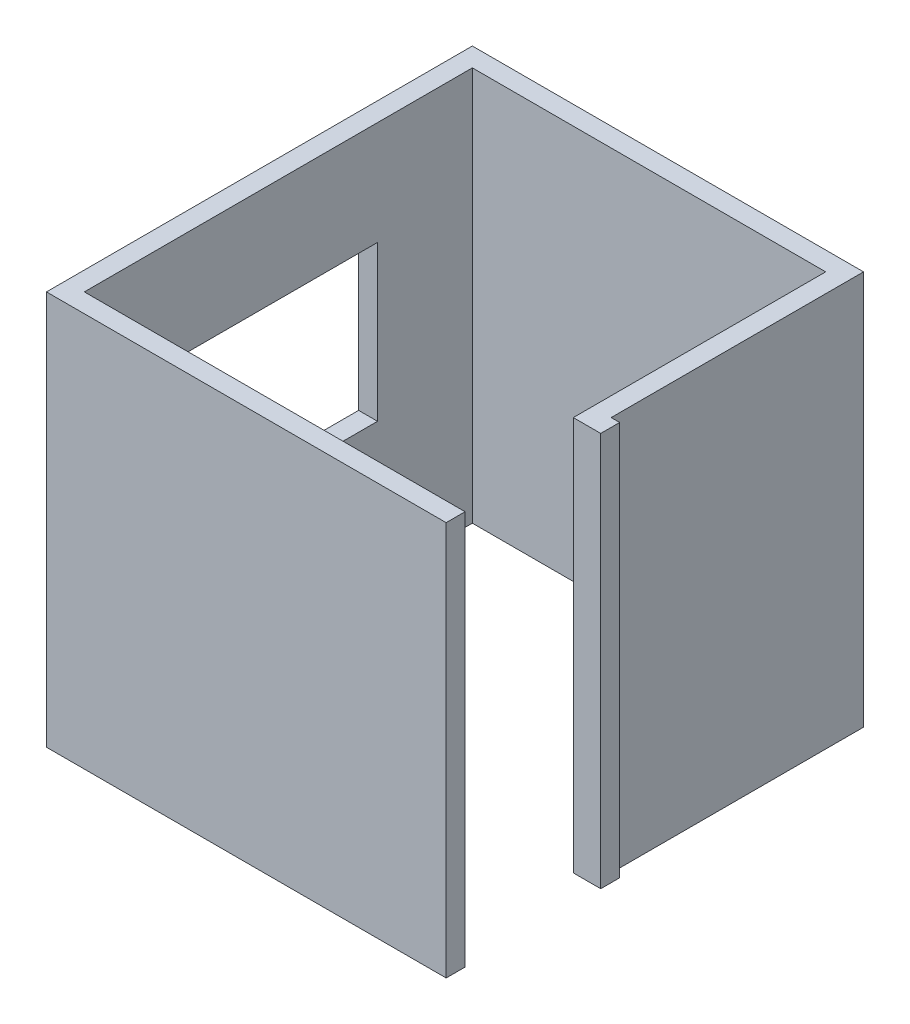
from build123d import *

# Parameters (mm, degrees)
EXTRUDE_1_DEPTH     = 2500
CUT_EXTRUDE_1_REACH = 2535.941
SKETCH_2_W          = 1370
SKETCH_2_H          = 982.146059398


with BuildPart() as part:
    # Эскиз1 → Вытянуть-Тонкостенный1 (new body)
    with BuildSketch(Plane(origin=(0, 0, 0), x_dir=(1, 0, 0), z_dir=(0, 1, 0))):
        Polygon((2413.940825756, 0), (0, 0), (0, 2460), (2240, 2460), (2240, 860), (2413.940825756, 860), (2413.940825756, 980), (2360, 980), (2360, 2580), (-120, 2580), (-120, -120), (2413.940825756, -120), align=None)
    extrude(amount=EXTRUDE_1_DEPTH)

    # Эскиз2 → Вырез-Вытянуть1 (cut, up to next)
    with BuildSketch(Plane.ZY.offset(120), mode=Mode.PRIVATE) as cut_extrude_1_sk1:
        with Locations((-1174, 1351.073029699)):
            Rectangle(SKETCH_2_W, SKETCH_2_H)
    cut_extrude_1_tool1 = extrude(cut_extrude_1_sk1.sketch, amount=-CUT_EXTRUDE_1_REACH, mode=Mode.PRIVATE) & part.part
    add(cut_extrude_1_tool1.solids().sort_by_distance((-120, 1351.07303, -1174))[0], mode=Mode.SUBTRACT)


solid = part.part
